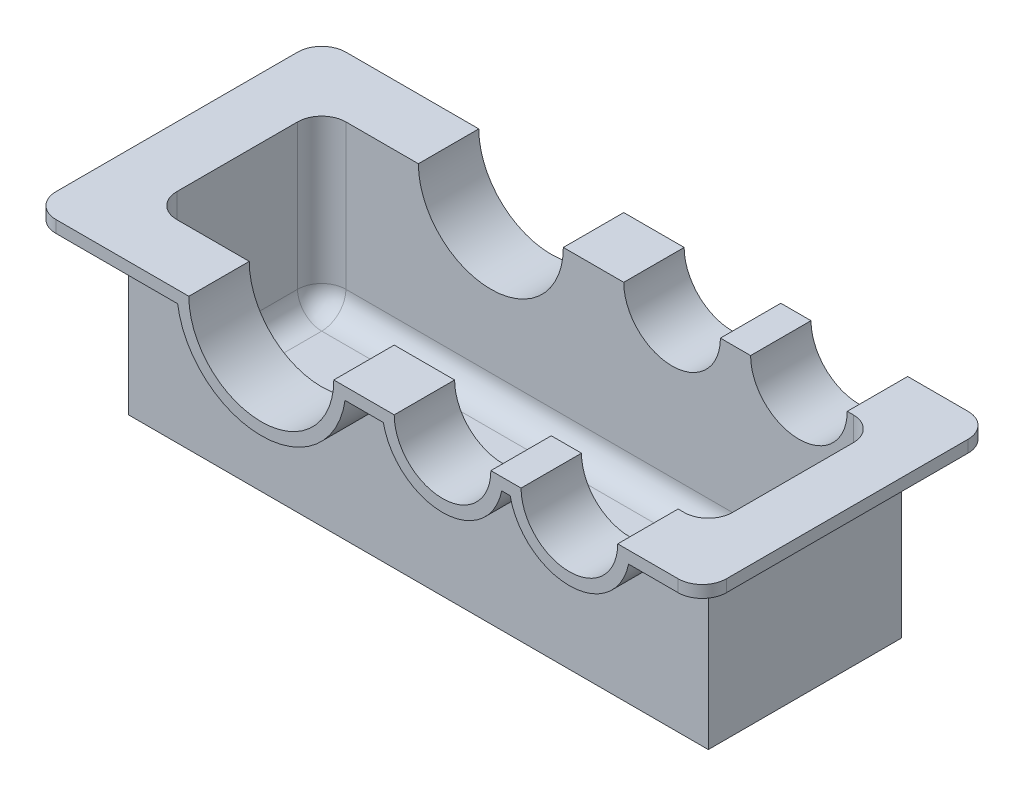
from build123d import *

# Parameters (mm, degrees)
SKETCH1_W               = 160
SKETCH1_H               = 150
BOSS_EXTRUDE1_DEPTH     = 240
SHELL1_T                = -10
SKETCH2_R               = 60
SKETCH2_R_2             = 40
CUT_EXTRUDE1_DEPTH      = 81
CUT_EXTRUDE1_DEPTH_BACK = 81
EXTRUDE_THIN1_DEPTH     = 120
SKETCH4_W               = 460
SKETCH4_H               = 140
CUT_EXTRUDE2_DEPTH      = 100
FILLET1_R               = 20
FILLET2_R               = 20


with BuildPart() as part:
    # Sketch1 → Boss-Extrude1 (new body, symmetric)
    with BuildSketch(Plane(origin=(0, 0, 0), x_dir=(0, 0, -1), z_dir=(1, 0, 0))):
        with Locations((0, 75)):
            Rectangle(SKETCH1_W, SKETCH1_H)
    extrude(amount=BOSS_EXTRUDE1_DEPTH, both=True)

    # Shell1
    shell1_openings = [part.faces().sort_by_distance(p)[0] for p in [
        (0, 150, 0),
    ]]
    offset(amount=SHELL1_T, openings=shell1_openings, kind=Kind.INTERSECTION)

    # Sketch2 → Cut-Extrude1 (cut, two sides)
    with BuildSketch(Plane.XY) as cut_extrude1_sk:
        with Locations((-90, 150)):
            Circle(SKETCH2_R)
        with Locations((60, 150)):
            Circle(SKETCH2_R_2)
        with Locations((165, 150)):
            Circle(SKETCH2_R_2)
    extrude(amount=CUT_EXTRUDE1_DEPTH, mode=Mode.SUBTRACT)
    extrude(cut_extrude1_sk.sketch, amount=-CUT_EXTRUDE1_DEPTH_BACK, mode=Mode.SUBTRACT)

    # Sketch3 → Extrude-Thin1 (add, symmetric)
    with BuildSketch(Plane.XY):
        with BuildLine():
            Line((275, 150), (205, 150))
            ThreePointArc((205, 150), (165, 110), (125, 150))
            Line((125, 150), (100, 150))
            ThreePointArc((100, 150), (60, 110), (20, 150))
            Line((20, 150), (-30, 150))
            ThreePointArc((-30, 150), (-90, 90), (-150, 150))
            Line((-150, 150), (-280, 150))
            Line((-280, 150), (-280, 140))
            Line((-280, 140), (-159.282032303, 140))
            ThreePointArc((-159.282032303, 140), (-90, 80), (-20.717967697, 140))
            Line((-20.717967697, 140), (11.010205144, 140))
            ThreePointArc((11.010205144, 140), (60, 100), (108.989794856, 140))
            Line((108.989794856, 140), (116.010205144, 140))
            ThreePointArc((116.010205144, 140), (165, 100), (213.989794856, 140))
            Line((213.989794856, 140), (275, 140))
            Line((275, 140), (275, 150))
        make_face()
    extrude(amount=EXTRUDE_THIN1_DEPTH, both=True)

    # Sketch4 → Cut-Extrude2 (cut)
    with BuildSketch(Plane(origin=(0, 150, 0), x_dir=(1, 0, 0), z_dir=(0, 1, 0))):
        Rectangle(SKETCH4_W, SKETCH4_H)
    extrude(amount=-CUT_EXTRUDE2_DEPTH, mode=Mode.SUBTRACT)

    # Fillet1
    fillet1_edges = [part.edges().sort_by_distance(p)[0] for p in [
        (275, 145, 120),
        (-280, 145, 120),
        (-280, 145, -120),
        (275, 145, -120),
    ]]
    fillet(fillet1_edges, radius=FILLET1_R)

    # Fillet2
    fillet2_edges = [part.edges().sort_by_distance(p)[0] for p in [
        (-230, 10, 0),
        (0, 10, 70),
        (-230, 80, -70),
        (0, 10, -70),
        (230, 10, 0),
        (230, 80, -70),
        (-230, 80, 70),
        (230, 80, 70),
    ]]
    fillet(fillet2_edges, radius=FILLET2_R)


solid = part.part
